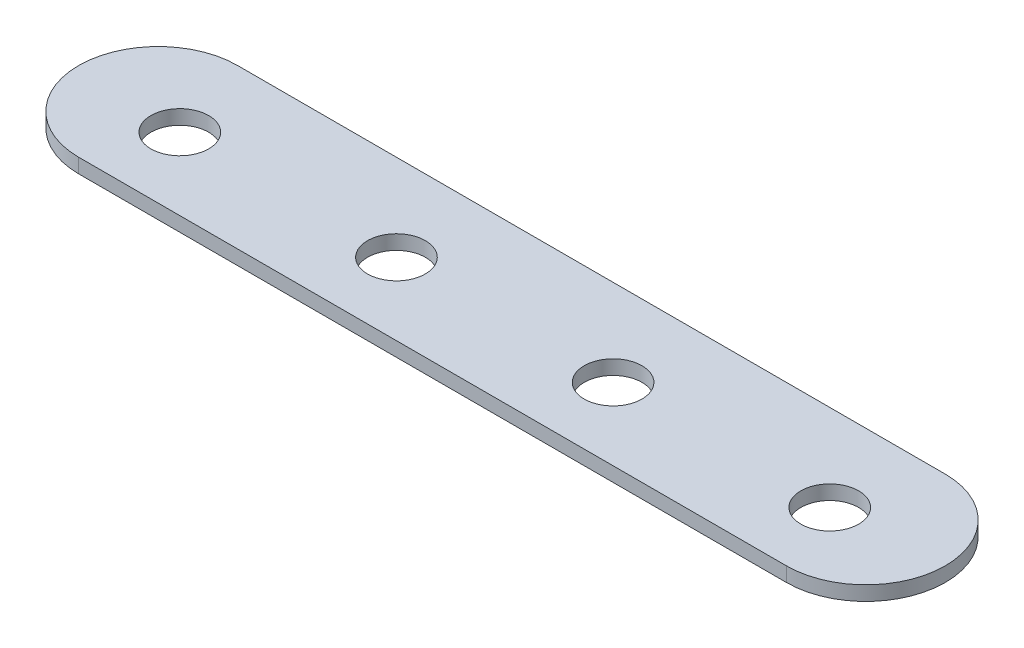
from build123d import *

# Parameters (mm, degrees)
SKETCH1_R           = 2
BOSS_EXTRUDE1_DEPTH = 1


with BuildPart() as part:
    # Sketch1 → Boss-Extrude1 (new body)
    with BuildSketch(Plane(origin=(0, 0, 0), x_dir=(1, 0, 0), z_dir=(0, 1, 0))):
        with BuildLine():
            Line((-5.5, 0), (-54.5, 0))
            ThreePointArc((-54.5, 0), (-60, 5.5), (-54.5, 11))
            Line((-54.5, 11), (-5.5, 11))
            ThreePointArc((-5.5, 11), (0, 5.5), (-5.5, 0))
        make_face()
        with Locations((-52.5, 5)):
            Circle(SKETCH1_R, mode=Mode.SUBTRACT)
        with Locations((-37.5, 5)):
            Circle(SKETCH1_R, mode=Mode.SUBTRACT)
        with Locations((-22.5, 5)):
            Circle(SKETCH1_R, mode=Mode.SUBTRACT)
        with Locations((-7.5, 5)):
            Circle(SKETCH1_R, mode=Mode.SUBTRACT)
    extrude(amount=BOSS_EXTRUDE1_DEPTH)


solid = part.part
